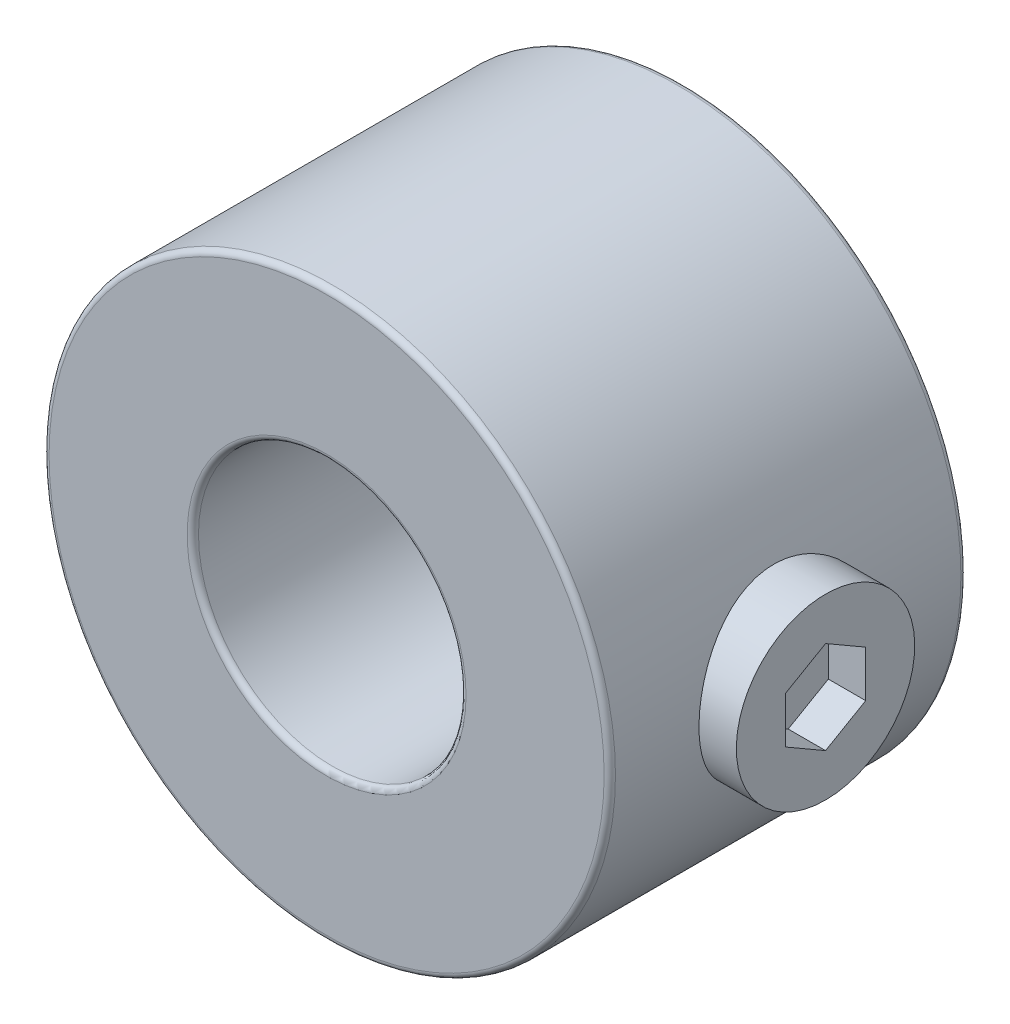
from build123d import *

# Parameters (mm, degrees)
SKETCH1_R          = 6.35
SKETCH1_R_2        = 3
EXTRUDE1_DEPTH     = 8
CUT_EXTRUDE1_REACH = 14.7
SKETCH2_R          = 2
SKETCH3_W          = 3.35
SKETCH3_H          = 2
CUT_EXTRUDE2_DEPTH = 0.8375
FILLET1_R          = 0.127


with BuildPart() as part:
    # Sketch1 → Extrude1 (new body)
    with BuildSketch(Plane.XY):
        Circle(SKETCH1_R)
        Circle(SKETCH1_R_2, mode=Mode.SUBTRACT)
    extrude(amount=EXTRUDE1_DEPTH)

    # Sketch2 → Cut-Extrude1 (cut, up to next)
    with BuildSketch(Plane(origin=(6.35, 0, 0), x_dir=(0, 0, -1), z_dir=(1, 0, 0)), mode=Mode.PRIVATE) as cut_extrude1_sk1:
        with Locations((-4, 0)):
            Circle(SKETCH2_R)
    cut_extrude1_tool1 = extrude(cut_extrude1_sk1.sketch, amount=-CUT_EXTRUDE1_REACH, mode=Mode.PRIVATE) & part.part
    add(cut_extrude1_tool1.solids().sort_by_distance((6.35, 0, 4))[0], mode=Mode.SUBTRACT)

    # Fillet1
    fillet1_edges = [part.edges().sort_by_distance(p)[0] for p in [
        (-6.35, 0, 0),
        (-6.35, 0, 8),
        (-3, 0, 0),
        (-3, 0, 8),
    ]]
    fillet(fillet1_edges, radius=FILLET1_R)


with BuildPart() as body_2:
    # Sketch3 → Revolve1 (revolve)
    with BuildSketch(Plane.XY.offset(4)):
        with Locations((5.5125, 1)):
            Rectangle(SKETCH3_W, SKETCH3_H)
    revolve(axis=Axis((3.8375, 0, 4), (1, 0, 0)))

    # Sketch4 → Cut-Extrude2 (cut)
    with BuildSketch(Plane(origin=(7.1875, 0, 0), x_dir=(0, 0, -1), z_dir=(1, 0, 0))):
        Polygon((-4, 1.039230485), (-4.9, 0.519615242), (-4.9, -0.519615242), (-4, -1.039230485), (-3.1, -0.519615242), (-3.1, 0.519615242), align=None)
    extrude(amount=-CUT_EXTRUDE2_DEPTH, mode=Mode.SUBTRACT)


solid = Compound([part.part, body_2.part])
